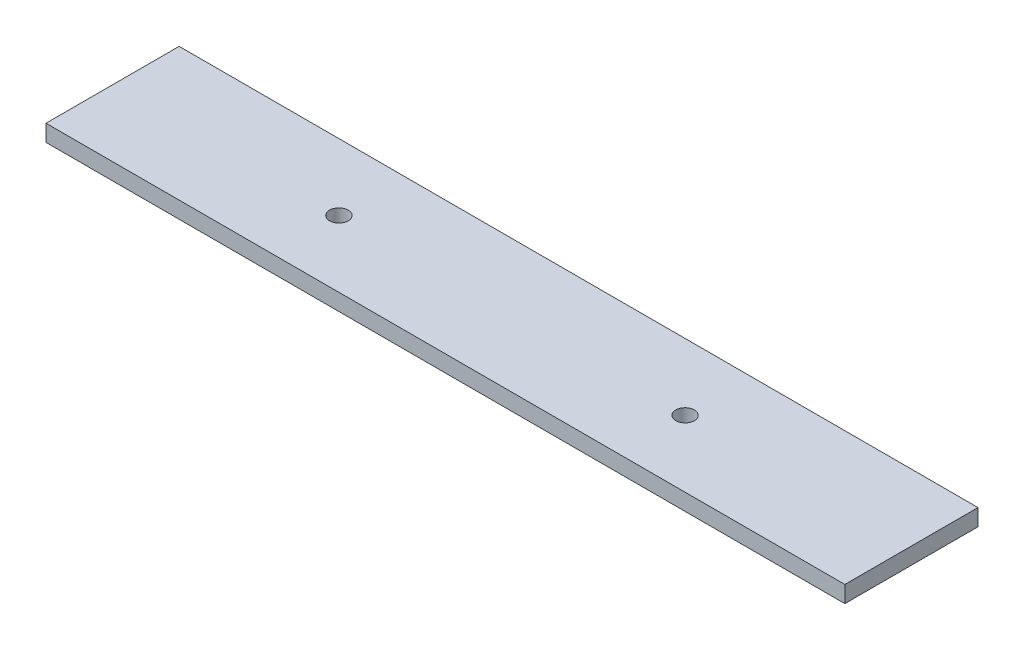
from build123d import *

# Parameters (mm, degrees)
SKETCH1_W           = 304.8
SKETCH1_H           = 50.8
SKETCH1_R           = 3.556
BOSS_EXTRUDE1_DEPTH = 6.35


with BuildPart() as part:
    # Sketch1 → Boss-Extrude1 (new body)
    with BuildSketch(Plane(origin=(0, 0, 0), x_dir=(1, 0, 0), z_dir=(0, 1, 0))):
        Rectangle(SKETCH1_W, SKETCH1_H)
        with Locations((-66.04, 0)):
            Circle(SKETCH1_R, mode=Mode.SUBTRACT)
        with Locations((66.04, 0)):
            Circle(SKETCH1_R, mode=Mode.SUBTRACT)
    extrude(amount=BOSS_EXTRUDE1_DEPTH)


solid = part.part
